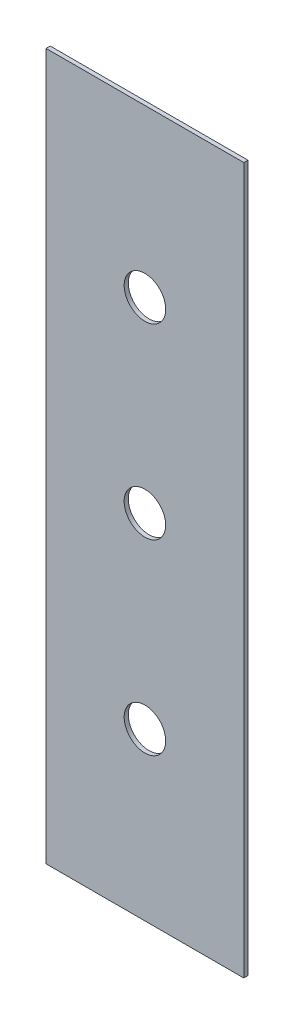
from build123d import *

# Parameters (mm, degrees)
ESBO_O1_W                = 47.590651375
ESBO_O1_H                = 170
ESBO_O1_R                = 5
RESSALTO_EXTRUS_O1_DEPTH = 1


with BuildPart() as part:
    # Esboço1 → Ressalto-extrusão1 (new body)
    with BuildSketch(Plane(origin=(0, 0, 0), x_dir=(-1, 0, 0), z_dir=(0, 0, 1))):
        with Locations((-275.84210192, -120)):
            Rectangle(ESBO_O1_W, ESBO_O1_H)
        with Locations((-275.84210192, -165)):
            Circle(ESBO_O1_R, mode=Mode.SUBTRACT)
        with Locations((-275.84210192, -120)):
            Circle(ESBO_O1_R, mode=Mode.SUBTRACT)
        with Locations((-275.84210192, -75)):
            Circle(ESBO_O1_R, mode=Mode.SUBTRACT)
    extrude(amount=RESSALTO_EXTRUS_O1_DEPTH)


solid = part.part
